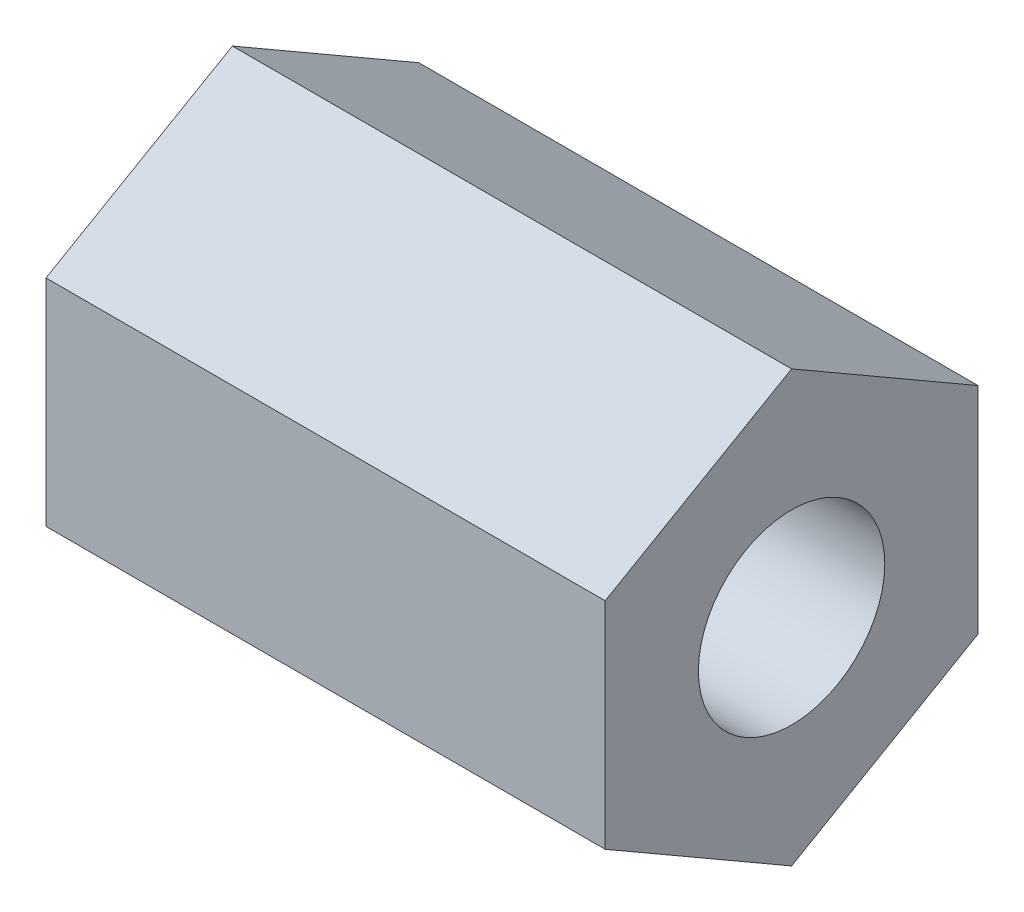
from build123d import *

# Parameters (mm, degrees)
SKETCH1_R           = 3.175
BOSS_EXTRUDE1_DEPTH = 19.05


with BuildPart() as part:
    # Sketch1 → Boss-Extrude1 (new body)
    with BuildSketch(Plane(origin=(0, 0, 0), x_dir=(0, 0, -1), z_dir=(1, 0, 0))):
        Polygon((0, 7.332348419), (-6.35, 3.666174209), (-6.35, -3.666174209), (0, -7.332348419), (6.35, -3.666174209), (6.35, 3.666174209), align=None)
        Circle(SKETCH1_R, mode=Mode.SUBTRACT)
    extrude(amount=BOSS_EXTRUDE1_DEPTH)


solid = part.part
